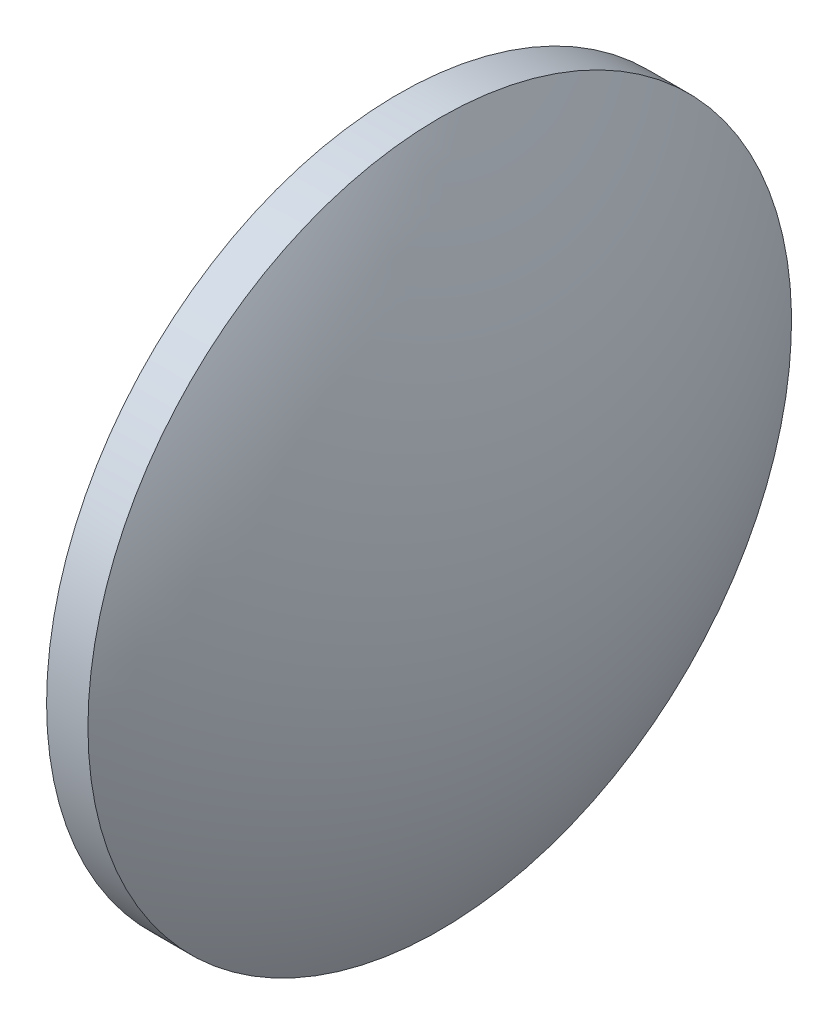
from build123d import *


with BuildPart() as part:
    # 草图1 → 旋转1 (revolve)
    with BuildSketch(Plane.XY):
        with BuildLine():
            Line((533.982155374, 140.681065344), (533.982155374, 153.181065344))
            Line((533.982155374, 153.181065344), (535.452155374, 153.181065344))
            ThreePointArc((535.452155374, 153.181065344), (537.861608134, 147.136351937), (538.682155374, 140.681065344))
            Line((538.682155374, 140.681065344), (533.982155374, 140.681065344))
        make_face()
    revolve(axis=Axis((529.240124133, 140.681065344, 0), (1, 0, 0)))


solid = part.part
